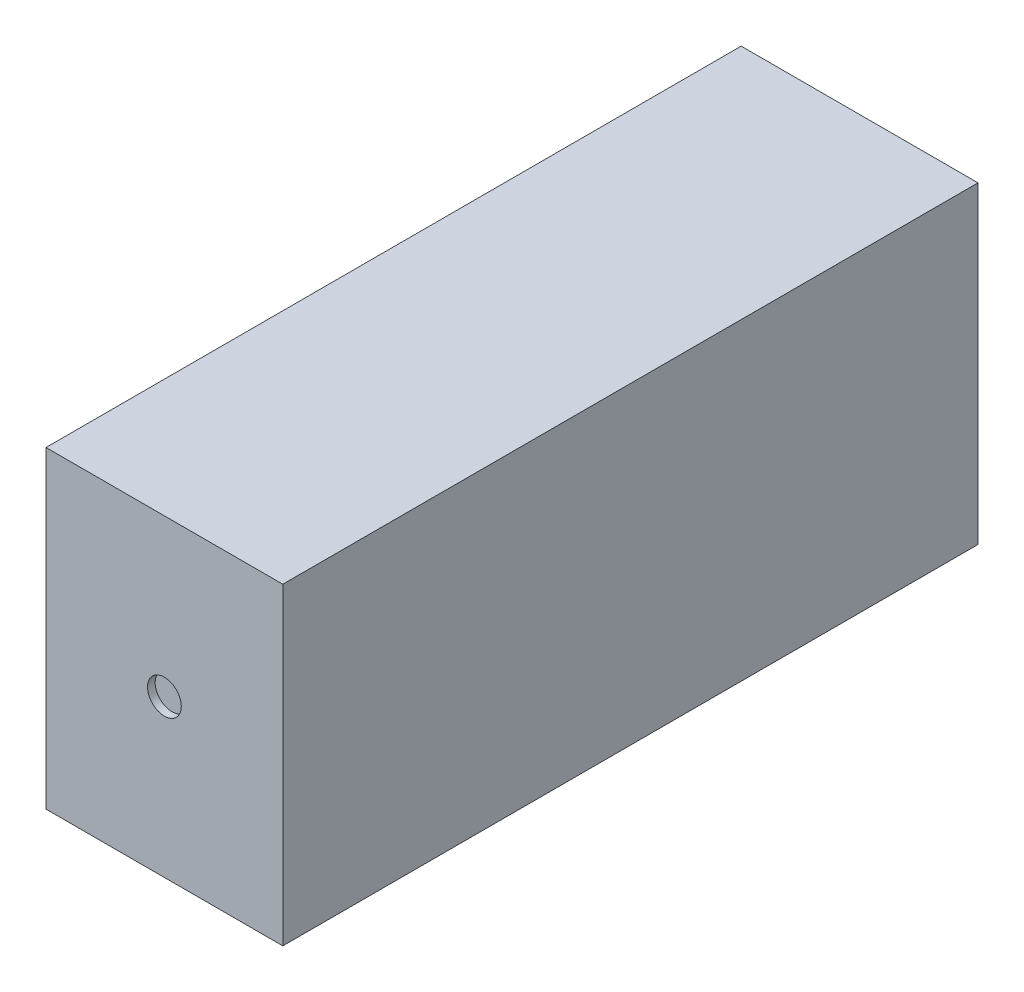
from build123d import *

# Parameters (mm, degrees)
SKETCH1_W           = 78.74
SKETCH1_H           = 104.14
BOSS_EXTRUDE1_DEPTH = 231.14
SKETCH2_R           = 5.614160658
CUT_EXTRUDE1_DEPTH  = 2.54


with BuildPart() as part:
    # Sketch1 → Boss-Extrude1 (new body)
    with BuildSketch(Plane.XY):
        with Locations((39.37, 52.07)):
            Rectangle(SKETCH1_W, SKETCH1_H)
    extrude(amount=BOSS_EXTRUDE1_DEPTH)

    # Sketch2 → Cut-Extrude1 (cut)
    with BuildSketch(Plane.XY.offset(231.14)):
        with Locations((39.37, 52.07)):
            Circle(SKETCH2_R)
    extrude(amount=-CUT_EXTRUDE1_DEPTH, mode=Mode.SUBTRACT)


solid = part.part
